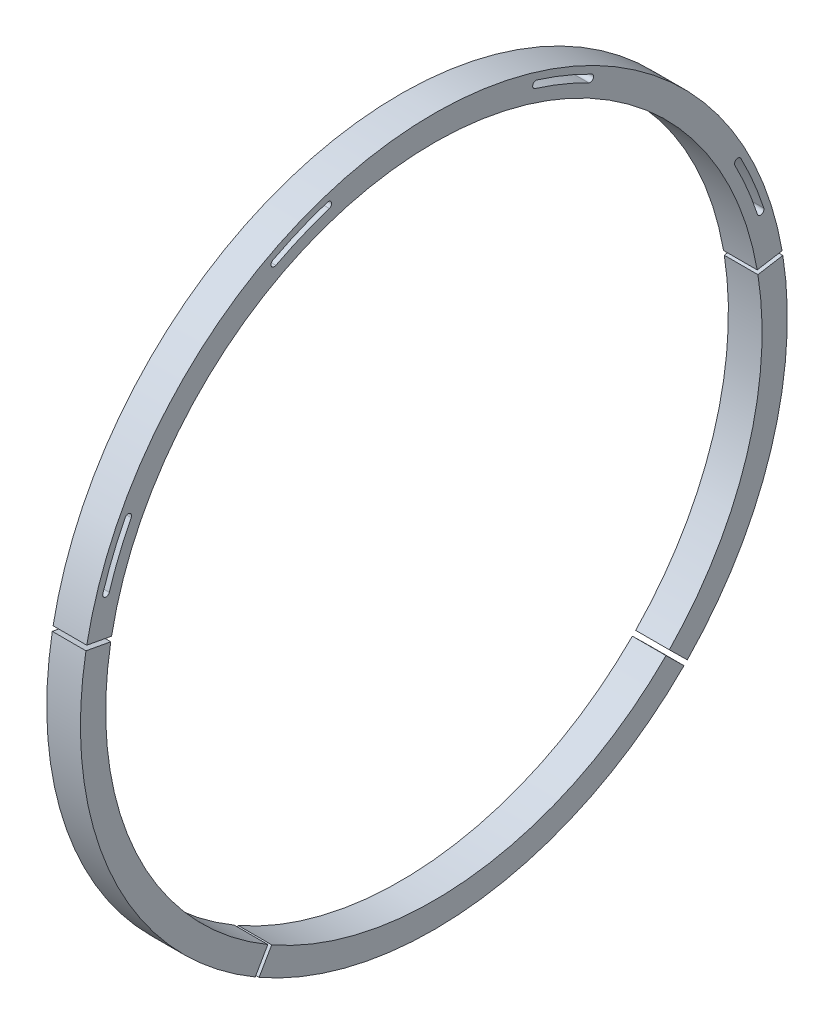
from build123d import *

# Parameters (mm, degrees)
BOSS_EXTRUDE1_DEPTH   = 20
BOSS_EXTRUDE1_2_DEPTH = 20
BOSS_EXTRUDE1_3_DEPTH = 20
BOSS_EXTRUDE1_4_DEPTH = 20
CUT_EXTRUDE1_DEPTH    = 31


with BuildPart() as part:
    # Sketch1 → Boss-Extrude1 (new body)
    with BuildSketch(Plane(origin=(0, 0, 0), x_dir=(0, 0, -1), z_dir=(1, 0, 0))):
        with BuildLine():
            Line((137.930678518, -137.840951548), (148.616838181, -148.36790559))
            ThreePointArc((148.616838181, -148.36790559), (142.431229175, -154.315731394), (136.007787822, -160.005880054))
            ThreePointArc((136.007787822, -160.005880054), (19.635454957, -209.080005999), (-103.838941685, -182.530748615))
            Line((-103.838941685, -182.530748615), (-96.340855434, -169.538902834))
            ThreePointArc((-96.340855434, -169.538902834), (18.325711034, -194.136983378), (126.363942746, -148.516510778))
            ThreePointArc((126.363942746, -148.516510778), (132.255070219, -143.295486326), (137.930678518, -137.840951548))
        make_face()
    extrude(amount=BOSS_EXTRUDE1_DEPTH)


with BuildPart() as body_2:
    # Sketch1 → Boss-Extrude1 2 (new body)
    with BuildSketch(Plane(origin=(0, 0, 0), x_dir=(0, 0, -1), z_dir=(1, 0, 0))):
        with BuildLine():
            Line((192.54165397, 30.86602479), (207.331289652, 33.372688401))
            ThreePointArc((207.331289652, 33.372688401), (200.256324225, -63.225031498), (150.581822575, -146.373203524))
            Line((150.581822575, -146.373203524), (139.895662912, -135.846249482))
            ThreePointArc((139.895662912, -135.846249482), (185.948616591, -58.720626595), (192.54165397, 30.86602479))
        make_face()
    extrude(amount=BOSS_EXTRUDE1_2_DEPTH)


with BuildPart() as body_3:
    # Sketch1 → Boss-Extrude1 3 (new body)
    with BuildSketch(Plane(origin=(0, 0, 0), x_dir=(0, 0, -1), z_dir=(1, 0, 0))):
        with BuildLine():
            Line((192.100705132, 33.501031145), (206.900670241, 35.945968532))
            ThreePointArc((206.900670241, 35.945968532), (1.849413133, 209.991856202), (-206.23546817, 39.584487729))
            Line((-206.23546817, 39.584487729), (-191.486773652, 36.848548359))
            ThreePointArc((-191.486773652, 36.848548359), (1.701674422, 194.992574998), (192.100705132, 33.501031145))
        make_face()
    extrude(amount=BOSS_EXTRUDE1_3_DEPTH)

    # Sketch6 → Cut-Extrude1 (cut, through all)
    with BuildSketch(Plane(origin=(30, 0, 0), x_dir=(0, 0, -1), z_dir=(1, 0, 0))):
        with BuildLine():
            ThreePointArc((-183.393976095, 93.822436187), (-190.726748281, 77.841553749), (-196.670022661, 61.293573779))
            ThreePointArc((-196.670022661, 61.293573779), (-195.355688205, 58.789072843), (-192.851187269, 60.103407298))
            ThreePointArc((-192.851187269, 60.103407298), (-187.023316276, 76.330067268), (-179.832928016, 92.000641309))
            ThreePointArc((-179.832928016, 92.000641309), (-180.702554617, 94.692062788), (-183.393976095, 93.822436187))
        make_face()
        with BuildLine():
            ThreePointArc((-63.336643271, 196.021604981), (-79.821886549, 189.906467577), (-95.725605017, 182.407808342))
            ThreePointArc((-95.725605017, 182.407808342), (-96.567179806, 179.707483941), (-93.866855405, 178.865909151))
            ThreePointArc((-93.866855405, 178.865909151), (-78.271947005, 186.218963353), (-62.106805537, 192.215360224))
            ThreePointArc((-62.106805537, 192.215360224), (-60.818602025, 194.733401469), (-63.336643271, 196.021604981))
        make_face()
        with BuildLine():
            ThreePointArc((93.822436187, 183.393976095), (77.841553749, 190.726748281), (61.293573779, 196.670022661))
            ThreePointArc((61.293573779, 196.670022661), (58.789072843, 195.355688205), (60.103407298, 192.851187269))
            ThreePointArc((60.103407298, 192.851187269), (76.330067268, 187.023316276), (92.000641309, 179.832928016))
            ThreePointArc((92.000641309, 179.832928016), (94.692062788, 180.702554617), (93.822436187, 183.393976095))
        make_face()
        with BuildLine():
            ThreePointArc((196.021604981, 63.336643271), (189.906467577, 79.821886549), (182.407808342, 95.725605017))
            ThreePointArc((182.407808342, 95.725605017), (179.707483941, 96.567179806), (178.865909151, 93.866855405))
            ThreePointArc((178.865909151, 93.866855405), (186.218963353, 78.271947005), (192.215360224, 62.106805537))
            ThreePointArc((192.215360224, 62.106805537), (194.733401469, 60.818602025), (196.021604981, 63.336643271))
        make_face()
    extrude(amount=-CUT_EXTRUDE1_DEPTH, mode=Mode.SUBTRACT)


with BuildPart() as body_4:
    # Sketch1 → Boss-Extrude1 4 (new body)
    with BuildSketch(Plane(origin=(0, 0, 0), x_dir=(0, 0, -1), z_dir=(1, 0, 0))):
        with BuildLine():
            Line((-98.654569067, -168.203079645), (-106.127730946, -181.209560245))
            ThreePointArc((-106.127730946, -181.209560245), (-190.703015105, -87.933838935), (-206.723208034, 36.952878914))
            Line((-206.723208034, 36.952878914), (-191.973642534, 34.221638946))
            ThreePointArc((-191.973642534, 34.221638946), (-177.087918896, -81.63864882), (-98.654569067, -168.203079645))
        make_face()
    extrude(amount=BOSS_EXTRUDE1_4_DEPTH)


solid = Compound([part.part, body_2.part, body_3.part, body_4.part])
